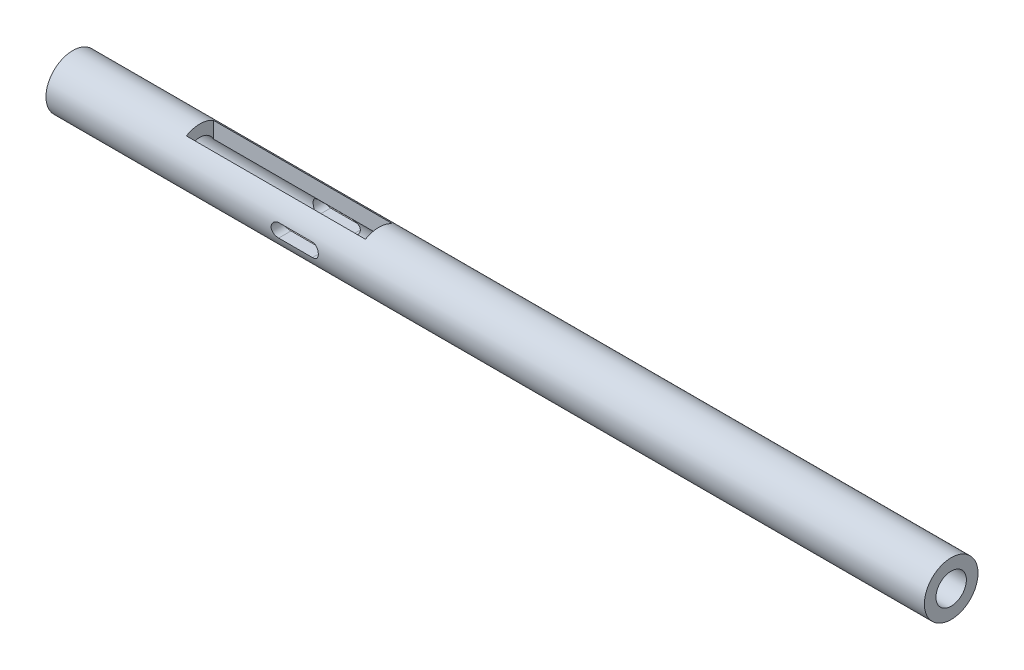
from build123d import *

# Parameters (mm, degrees)
SKETCH2_R                                          = 3.96875
SKETCH2_R_2                                        = 2.25
BODY_DEPTH                                         = 130
CAVITY_FOR_SLIDER_DEPTH                            = 131.121104949
CAVITY_FOR_SLIDER_DEPTH_BACK                       = 131.121104949
SKETCH4_W                                          = 26.495455659
SKETCH4_H                                          = 4
SLIDER_TRACK_FOR_M2_SCREW_5_64_END_MILL_DEPTH      = 131.121104949
SLIDER_TRACK_FOR_M2_SCREW_5_64_END_MILL_DEPTH_BACK = 131.121104949


with BuildPart() as part:
    # Sketch2 → Body (new body)
    with BuildSketch(Plane(origin=(0, 0, 0), x_dir=(0, 0, -1), z_dir=(1, 0, 0))):
        Circle(SKETCH2_R)
        Circle(SKETCH2_R_2, mode=Mode.SUBTRACT)
    extrude(amount=BODY_DEPTH)

    # Sketch4 → cavity for slider (cut, two sides: drawn at the far end of the back side and taken through both)
    with BuildSketch(Plane(origin=(0, 0, 0), x_dir=(1, 0, 0), z_dir=(0, 1, 0)).offset(-CAVITY_FOR_SLIDER_DEPTH_BACK)):
        with Locations((32.060413051, 0)):
            Rectangle(SKETCH4_W, SKETCH4_H)
    extrude(amount=CAVITY_FOR_SLIDER_DEPTH + CAVITY_FOR_SLIDER_DEPTH_BACK, mode=Mode.SUBTRACT)

    # Sketch12 → slider track for M2 screw 5_64 end mill (cut, two sides: drawn at the far end of the back side and taken through both)
    with BuildSketch(Plane.XY.offset(-SLIDER_TRACK_FOR_M2_SCREW_5_64_END_MILL_DEPTH_BACK)):
        with BuildLine():
            Line((39.315953381, -0.9921875), (34.315953381, -0.9921875))
            ThreePointArc((34.315953381, -0.9921875), (33.323765881, 0), (34.315953381, 0.9921875))
            Line((34.315953381, 0.9921875), (39.315953381, 0.9921875))
            ThreePointArc((39.315953381, 0.9921875), (40.308140881, 0), (39.315953381, -0.9921875))
        make_face()
    extrude(amount=SLIDER_TRACK_FOR_M2_SCREW_5_64_END_MILL_DEPTH + SLIDER_TRACK_FOR_M2_SCREW_5_64_END_MILL_DEPTH_BACK, mode=Mode.SUBTRACT)


solid = part.part
